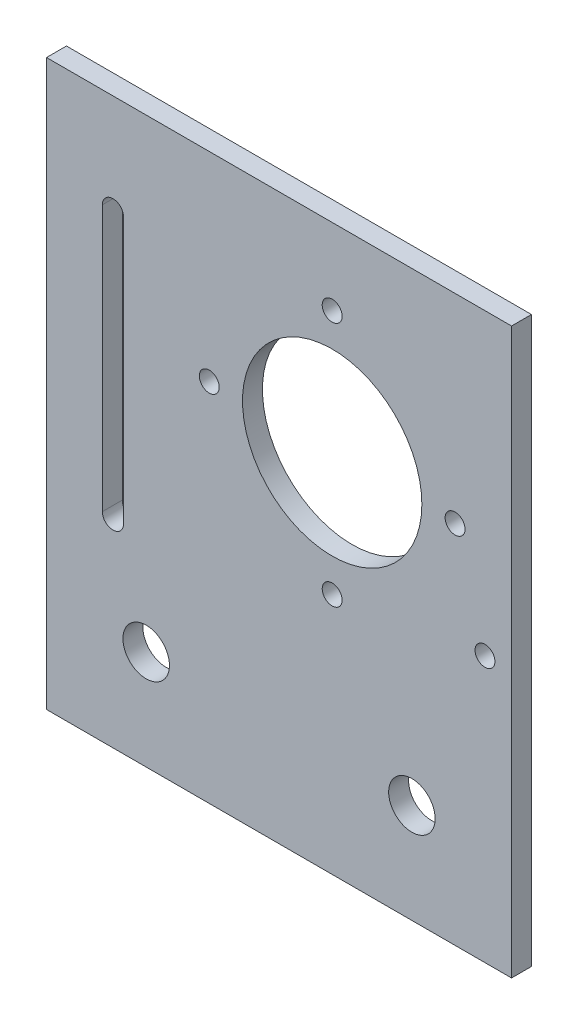
from build123d import *

# Parameters (mm, degrees)
SKETCH1_W           = 70
SKETCH1_H           = 85
SKETCH1_R           = 1.5
SKETCH1_R_2         = 13.5
SKETCH1_R_3         = 3.5
BOSS_EXTRUDE1_DEPTH = 3


with BuildPart() as part:
    # Sketch1 → Boss-Extrude1 (new body)
    with BuildSketch(Plane.XY):
        Rectangle(SKETCH1_W, SKETCH1_H)
        with Locations((31, -2.5)):
            Circle(SKETCH1_R, mode=Mode.SUBTRACT)
        with Locations((8, 12.5)):
            Circle(SKETCH1_R_2, mode=Mode.SUBTRACT)
        with Locations((-20, -27.5)):
            Circle(SKETCH1_R_3, mode=Mode.SUBTRACT)
        with Locations((20, -27.5)):
            Circle(SKETCH1_R_3, mode=Mode.SUBTRACT)
        with Locations((8, 31)):
            Circle(SKETCH1_R, mode=Mode.SUBTRACT)
        with Locations((26.5, 12.5)):
            Circle(SKETCH1_R, mode=Mode.SUBTRACT)
        with Locations((8, -6)):
            Circle(SKETCH1_R, mode=Mode.SUBTRACT)
        with Locations((-10.5, 12.5)):
            Circle(SKETCH1_R, mode=Mode.SUBTRACT)
        with BuildLine():
            Line((-26.6, 27.5), (-26.6, -12.5))
            ThreePointArc((-26.6, -12.5), (-25, -14.1), (-23.4, -12.5))
            Line((-23.4, -12.5), (-23.4, 27.5))
            ThreePointArc((-23.4, 27.5), (-25, 29.1), (-26.6, 27.5))
        make_face(mode=Mode.SUBTRACT)
    extrude(amount=BOSS_EXTRUDE1_DEPTH)


solid = part.part
